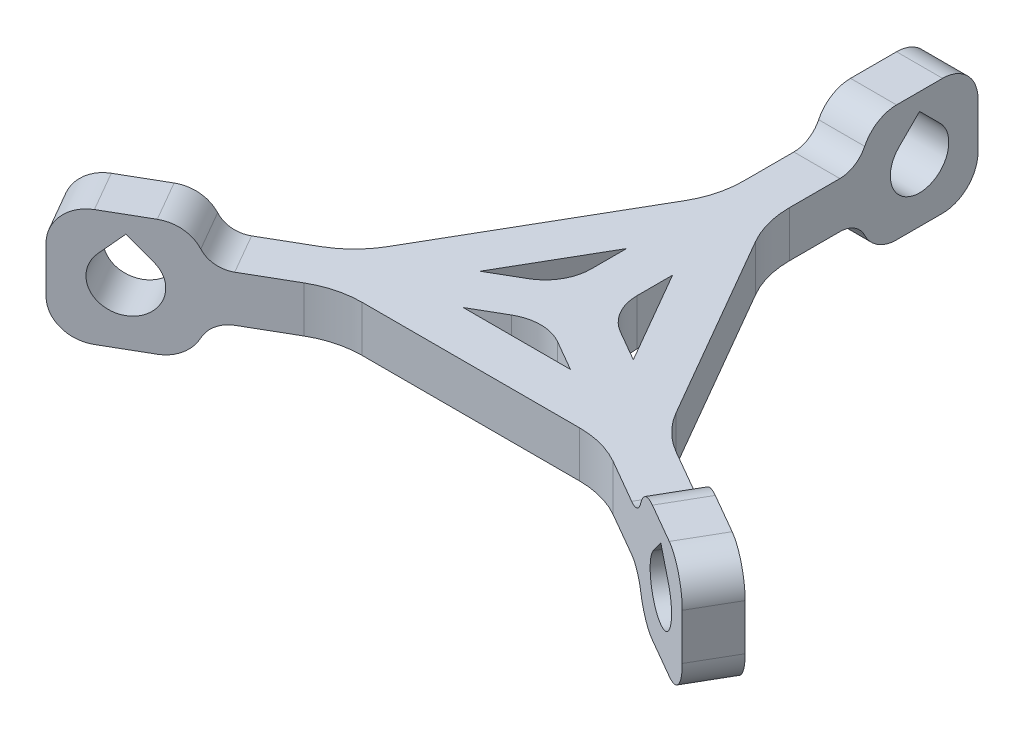
from build123d import *

# Parameters (mm, degrees)
SALIENTE_EXTRUIR1_DEPTH = 2.5
CROQUIS2_W              = 5
CROQUIS2_H              = 12.7
SALIENTE_EXTRUIR2_DEPTH = 6.350000000000001
CORTAR_EXTRUIR1_REACH   = 52.655
CORTAR_EXTRUIR2_REACH   = 52.655
MATRIZC7_COUNT          = 3
REDONDEO3_R             = 3
REDONDEO4_R             = 3
REDONDEO5_R             = 3
REDONDEO6_R             = 3
REDONDEO7_R             = 3
REDONDEO8_R             = 3


with BuildPart() as part:
    # Croquis1 → Saliente-Extruir1 (new, symmetric)
    with BuildSketch(Plane(origin=(0, 0, 0), x_dir=(1, 0, 0), z_dir=(0, 1, 0))):
        with BuildLine():
            Line((-2.5, 28.650000000000002), (2.5, 28.650000000000002))
            Line((2.5, 28.650000000000002), (2.5, 20.849364905389077))
            ThreePointArc((2.5, 20.849364905389077), (2.8407417371092976, 18.26117445436386), (3.8397459621556003, 15.84936490538906))
            Line((3.8397459621556003, 15.84936490538906), (15.64582562299427, -4.599364905389191))
            ThreePointArc((15.64582562299427, -4.599364905389191), (17.235011848973173, -6.670432717254639), (19.306079660838602, -8.259618943233573))
            Line((19.306079660838602, -8.259618943233573), (26.061627818424082, -12.159936490539094))
            Line((26.061627818424082, -12.159936490539094), (23.561627818424125, -16.490063509461137))
            Line((23.561627818424125, -16.490063509461137), (16.806079660838638, -12.589745962155668))
            ThreePointArc((16.806079660838638, -12.589745962155668), (14.394270111863824, -11.590741737109344), (11.80607966083859, -11.25000000000002))
            Line((11.80607966083859, -11.25000000000002), (-11.806079660838877, -11.250000000000021))
            ThreePointArc((-11.806079660838877, -11.250000000000021), (-14.394270111864046, -11.590741737109328), (-16.806079660838808, -12.589745962155595))
            Line((-16.806079660838808, -12.589745962155595), (-23.561627818424295, -16.490063509460935))
            Line((-23.561627818424295, -16.490063509460935), (-26.061627818424316, -12.15993649053858))
            Line((-26.061627818424316, -12.15993649053858), (-19.30607966083857, -8.259618943233107))
            ThreePointArc((-19.30607966083857, -8.259618943233107), (-17.235011848973045, -6.670432717254254), (-15.645825622994131, -4.5993649053887635))
            Line((-15.645825622994131, -4.5993649053887635), (-3.8397459621555967, 15.849364905389269))
            ThreePointArc((-3.8397459621555967, 15.849364905389269), (-2.8407417371093064, 18.26117445436405), (-2.5000000000000004, 20.84936490538924))
            Line((-2.5000000000000004, 20.84936490538924), (-2.5, 28.650000000000002))
        make_face()
        with BuildLine():
            Line((4.999999999999967, -1.648e-14), (8.325317547305488, -1.919872981077918))
            Line((8.325317547305488, -1.919872981077918), (2.5, 8.169872981077836))
            Line((2.5, 8.169872981077836), (2.5000000000000004, 4.330127018922162))
            ThreePointArc((2.5000000000000004, 4.330127018922162), (3.16987298107781, 1.8301270189221883), (4.999999999999967, -1.648e-14))
        make_face(mode=Mode.SUBTRACT)
        with BuildLine():
            Line((-2.499999999999762, -4.330127018922147), (-5.825317547305628, -6.250000000000082))
            Line((-5.825317547305628, -6.250000000000082), (5.825317547305489, -6.249999999999961))
            Line((5.825317547305489, -6.249999999999961), (2.5000000000002185, -4.3301270189221945))
            ThreePointArc((2.5000000000002185, -4.3301270189221945), (1.9836e-13, -3.660254037844239), (-2.499999999999762, -4.330127018922147))
        make_face(mode=Mode.SUBTRACT)
        with BuildLine():
            Line((-2.5000000000000004, 4.330127018922227), (-2.5, 8.169872981077782))
            Line((-2.5, 8.169872981077782), (-8.325317547305644, -1.9198729810777775))
            Line((-8.325317547305644, -1.9198729810777775), (-5.000000000000053, 0))
            ThreePointArc((-5.000000000000053, 0), (-3.1698729810778152, 1.8301270189221972), (-2.5000000000000004, 4.330127018922227))
        make_face(mode=Mode.SUBTRACT)
    extrude(amount=SALIENTE_EXTRUIR1_DEPTH, both=True)

    # Croquis2 → Saliente-Extruir2 (add, symmetric)
    with BuildSketch(Plane(origin=(0, 0, 0), x_dir=(1, 0, 0), z_dir=(0, 1, 0))):
        with Locations((0, 35)):
            Rectangle(CROQUIS2_W, CROQUIS2_H)
    saliente_extruir2 = extrude(amount=SALIENTE_EXTRUIR2_DEPTH, both=True)

    # Croquis3 → Cortar-Extruir1 (cut, up to next)
    with BuildSketch(Plane(origin=(2.5, 0, 0), x_dir=(0, 0, -1), z_dir=(1, 0, 0)), mode=Mode.PRIVATE) as cortar_extruir1_sk1:
        with BuildLine():
            Line((32.754935969732706, 2.2450640302672804), (35, 4.490128060534589))
            Line((35, 4.490128060534589), (37.245064030267294, 2.245064030267292))
            ThreePointArc((37.245064030267294, 2.245064030267292), (35.00000000000001, -3.174999999999998), (32.754935969732706, 2.2450640302672804))
        make_face()
    cortar_extruir1_tool1 = extrude(cortar_extruir1_sk1.sketch, amount=-CORTAR_EXTRUIR1_REACH, mode=Mode.PRIVATE) & part.part
    cortar_extruir1 = cortar_extruir1_tool1.solids().sort_by_distance((2.5, 0.222977, -35))[0]
    add(cortar_extruir1, mode=Mode.SUBTRACT)

    # Croquis4 → Cortar-Extruir2 (cut, up to next)
    with BuildSketch(Plane.ZY.offset(2.5000000000000018), mode=Mode.PRIVATE) as cortar_extruir2_sk1:
        with BuildLine():
            Line((-41.35, 6.350000000000001), (-37.50000000000001, 6.350000000000001))
            ThreePointArc((-37.50000000000001, 6.350000000000001), (-40.22236110756822, 5.222361107568213), (-41.35, 2.500000000000002))
            Line((-41.35, 2.500000000000002), (-41.35, 6.350000000000001))
        make_face()
    cortar_extruir2_tool1 = extrude(cortar_extruir2_sk1.sketch, amount=-CORTAR_EXTRUIR2_REACH, mode=Mode.PRIVATE) & part.part
    # Croquis4 → Cortar-Extruir2 (cut, up to next)
    with BuildSketch(Plane.ZY.offset(2.5000000000000018), mode=Mode.PRIVATE) as cortar_extruir2_sk2:
        with BuildLine():
            Line((-32.5, 6.350000000000001), (-28.650000000000002, 6.350000000000001))
            Line((-28.650000000000002, 6.350000000000001), (-28.650000000000002, 2.5))
            ThreePointArc((-28.650000000000002, 2.5), (-29.777638892431792, 5.222361107568209), (-32.5, 6.350000000000001))
        make_face()
    cortar_extruir2_tool2 = extrude(cortar_extruir2_sk2.sketch, amount=-CORTAR_EXTRUIR2_REACH, mode=Mode.PRIVATE) & part.part
    # Croquis4 → Cortar-Extruir2 (cut, up to next)
    with BuildSketch(Plane.ZY.offset(2.5000000000000018), mode=Mode.PRIVATE) as cortar_extruir2_sk3:
        with BuildLine():
            Line((-41.35, -2.500000000000002), (-41.35, -6.350000000000001))
            Line((-41.35, -6.350000000000001), (-37.50000000000001, -6.350000000000001))
            ThreePointArc((-37.50000000000001, -6.350000000000001), (-40.22236110756821, -5.222361107568203), (-41.35, -2.500000000000002))
        make_face()
    cortar_extruir2_tool3 = extrude(cortar_extruir2_sk3.sketch, amount=-CORTAR_EXTRUIR2_REACH, mode=Mode.PRIVATE) & part.part
    # Croquis4 → Cortar-Extruir2 (cut, up to next)
    with BuildSketch(Plane.ZY.offset(2.5000000000000018), mode=Mode.PRIVATE) as cortar_extruir2_sk4:
        with BuildLine():
            Line((-28.650000000000002, -2.5000000000000004), (-28.650000000000002, -6.350000000000001))
            Line((-28.650000000000002, -6.350000000000001), (-32.5, -6.350000000000001))
            ThreePointArc((-32.5, -6.350000000000001), (-29.777638892431792, -5.222361107568209), (-28.650000000000002, -2.5000000000000004))
        make_face()
    cortar_extruir2_tool4 = extrude(cortar_extruir2_sk4.sketch, amount=-CORTAR_EXTRUIR2_REACH, mode=Mode.PRIVATE) & part.part
    cortar_extruir2_1 = cortar_extruir2_tool1.solids().sort_by_distance((-2.5, 5.490033, -40.490033))[0]
    add(cortar_extruir2_1, mode=Mode.SUBTRACT)
    cortar_extruir2_2 = cortar_extruir2_tool2.solids().sort_by_distance((-2.5, 5.490033, -29.509967))[0]
    add(cortar_extruir2_2, mode=Mode.SUBTRACT)
    cortar_extruir2_3 = cortar_extruir2_tool3.solids().sort_by_distance((-2.5, -5.490033, -40.490033))[0]
    add(cortar_extruir2_3, mode=Mode.SUBTRACT)
    cortar_extruir2_4 = cortar_extruir2_tool4.solids().sort_by_distance((-2.5, -5.490033, -29.509967))[0]
    add(cortar_extruir2_4, mode=Mode.SUBTRACT)
    cortar_extruir2 = cortar_extruir2_1 + cortar_extruir2_2 + cortar_extruir2_3 + cortar_extruir2_4  # Cortar-Extruir2 as one shape, for the pattern or mirror that repeats it

    # MatrizC7: Saliente-Extruir2, Cortar-Extruir1, Cortar-Extruir2 ×3 about axis
    matrizc7_axis = Axis((-4.13e-15, 0, 3.06e-15), (0, 1, 0))
    add([saliente_extruir2.rotate(matrizc7_axis, i * 360 / MATRIZC7_COUNT) for i in range(1, MATRIZC7_COUNT)])
    add([cortar_extruir1.rotate(matrizc7_axis, i * 360 / MATRIZC7_COUNT) for i in range(1, MATRIZC7_COUNT)], mode=Mode.SUBTRACT)
    add([cortar_extruir2.rotate(matrizc7_axis, i * 360 / MATRIZC7_COUNT) for i in range(1, MATRIZC7_COUNT)], mode=Mode.SUBTRACT)

    # Redondeo3
    redondeo3_edges = [part.edges().sort_by_distance(p)[0] for p in [
        (0, 2.5, -28.650000000000002),
    ]]
    fillet(redondeo3_edges, radius=REDONDEO3_R)

    # Redondeo4
    redondeo4_edges = [part.edges().sort_by_distance(p)[0] for p in [
        (-24.811627818424306, 2.5, 14.324999999999758),
    ]]
    fillet(redondeo4_edges, radius=REDONDEO4_R)

    # Redondeo5
    redondeo5_edges = [part.edges().sort_by_distance(p)[0] for p in [
        (24.811627818424103, 2.5, 14.325000000000117),
    ]]
    fillet(redondeo5_edges, radius=REDONDEO5_R)

    # Redondeo6
    redondeo6_edges = [part.edges().sort_by_distance(p)[0] for p in [
        (-24.811627818424306, -2.5, 14.324999999999758),
    ]]
    fillet(redondeo6_edges, radius=REDONDEO6_R)

    # Redondeo7
    redondeo7_edges = [part.edges().sort_by_distance(p)[0] for p in [
        (0, -2.5, -28.650000000000002),
    ]]
    fillet(redondeo7_edges, radius=REDONDEO7_R)

    # Redondeo8
    redondeo8_edges = [part.edges().sort_by_distance(p)[0] for p in [
        (24.811627818424103, -2.5, 14.325000000000117),
    ]]
    fillet(redondeo8_edges, radius=REDONDEO8_R)


solid = part.part
